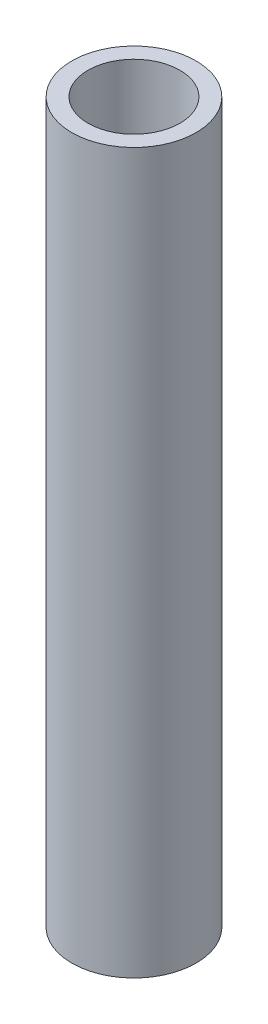
from build123d import *

# Parameters (mm, degrees)
SKETCH1_R                    = 19.05
BOSS_EXTRUDE1_DEPTH          = 220.472
SKETCH2_R                    = 12.7
CUT_EXTRUDE1_DEPTH           = 221.472
F_1_1_4_7_TAPPED_HOLE1_D     = 28.17876
F_1_1_4_7_TAPPED_HOLE1_DEPTH = 49.022
F_1_1_4_7_TAPPED_HOLE1_TIP   = 8.465753589
F_1_1_4_7_TAPPED_HOLE2_D     = 28.17876
F_1_1_4_7_TAPPED_HOLE2_DEPTH = 49.022
F_1_1_4_7_TAPPED_HOLE2_TIP   = 8.465753589


with BuildPart() as part:
    # Sketch1 → Boss-Extrude1 (new body)
    with BuildSketch(Plane(origin=(0, 0, 0), x_dir=(1, 0, 0), z_dir=(0, 1, 0))):
        Circle(SKETCH1_R)
    extrude(amount=BOSS_EXTRUDE1_DEPTH)

    # Sketch2 → Cut-Extrude1 (cut, through all)
    with BuildSketch(Plane(origin=(0, 220.472, 0), x_dir=(1, 0, 0), z_dir=(0, 1, 0))):
        Circle(SKETCH2_R)
    extrude(amount=-CUT_EXTRUDE1_DEPTH, mode=Mode.SUBTRACT)

    # 1-1/4-7 Tapped Hole1
    with Locations(Plane(origin=(0, 220.472, 0), x_dir=(1, 0, 0), z_dir=(0, 1, 0))):
        with Locations((0, 0)):
            Hole(F_1_1_4_7_TAPPED_HOLE1_D / 2, depth=F_1_1_4_7_TAPPED_HOLE1_DEPTH)
            with Locations((0, 0, -(F_1_1_4_7_TAPPED_HOLE1_DEPTH + F_1_1_4_7_TAPPED_HOLE1_TIP / 2))):  # 118° drill point
                Cone(0, F_1_1_4_7_TAPPED_HOLE1_D / 2, F_1_1_4_7_TAPPED_HOLE1_TIP, mode=Mode.SUBTRACT)

    # 1-1/4-7 Tapped Hole2
    with Locations(Plane(origin=(0, 0, 0), x_dir=(-1, 0, 0), z_dir=(0, -1, 0))):
        with Locations((0, 0)):
            Hole(F_1_1_4_7_TAPPED_HOLE2_D / 2, depth=F_1_1_4_7_TAPPED_HOLE2_DEPTH)
            with Locations((0, 0, -(F_1_1_4_7_TAPPED_HOLE2_DEPTH + F_1_1_4_7_TAPPED_HOLE2_TIP / 2))):  # 118° drill point
                Cone(0, F_1_1_4_7_TAPPED_HOLE2_D / 2, F_1_1_4_7_TAPPED_HOLE2_TIP, mode=Mode.SUBTRACT)


solid = part.part
